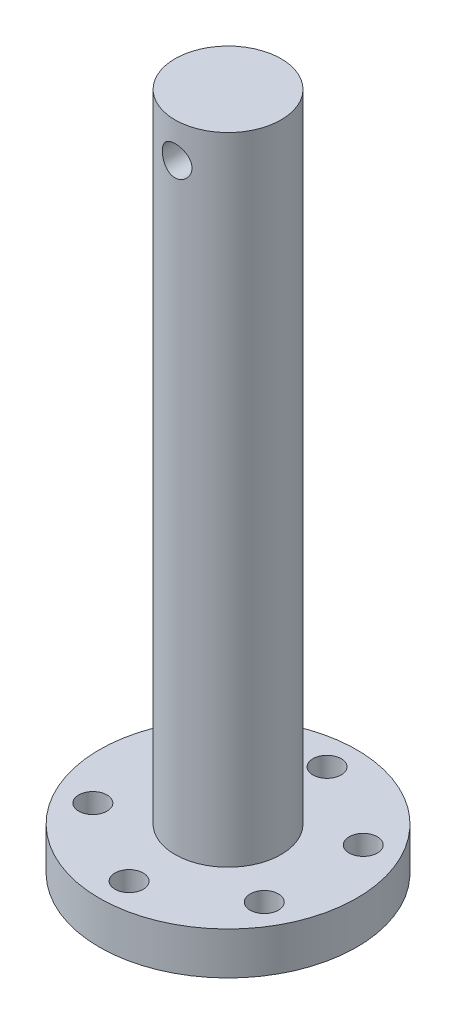
from build123d import *

# Parameters (mm, degrees)
SKETCH1_R           = 18.2
BOSS_EXTRUDE1_DEPTH = 6
SKETCH3_R           = 2
CUT_EXTRUDE1_DEPTH  = 10
CIRPATTERN1_COUNT   = 6
SKETCH4_R           = 7.5
BOSS_EXTRUDE2_DEPTH = 90
SKETCH9_R           = 2.1
CUT_EXTRUDE2_DEPTH  = 26.7


with BuildPart() as part:
    # Sketch1 → Boss-Extrude1 (new body)
    with BuildSketch(Plane(origin=(0, 0, 0), x_dir=(1, 0, 0), z_dir=(0, 1, 0))):
        Circle(SKETCH1_R)
    extrude(amount=BOSS_EXTRUDE1_DEPTH)

    # Sketch3 → Cut-Extrude1 (cut)
    with BuildSketch(Plane(origin=(0, 6, 0), x_dir=(1, 0, 0), z_dir=(0, 1, 0))):
        with Locations((0, 14)):
            Circle(SKETCH3_R)
    cut_extrude1 = extrude(amount=-CUT_EXTRUDE1_DEPTH, mode=Mode.SUBTRACT)

    # CirPattern1: Cut-Extrude1 ×6 about axis
    cirpattern1_axis = Axis((0, 0, 0), (0, 1, 0))
    for i in range(1, CIRPATTERN1_COUNT):
        add(cut_extrude1.rotate(cirpattern1_axis, i * 360 / CIRPATTERN1_COUNT), mode=Mode.SUBTRACT)

    # Sketch4 → Boss-Extrude2 (add)
    with BuildSketch(Plane(origin=(0, 6, 0), x_dir=(1, 0, 0), z_dir=(0, 1, 0))):
        Circle(SKETCH4_R)
    extrude(amount=BOSS_EXTRUDE2_DEPTH)

    # Sketch9 → Cut-Extrude2 (cut, through all)
    with BuildSketch(Plane(origin=(0, 0, -7.5), x_dir=(-1, 0, 0), z_dir=(0, 0, -1))):
        with Locations((0, 91)):
            Circle(SKETCH9_R)
    extrude(amount=-CUT_EXTRUDE2_DEPTH, mode=Mode.SUBTRACT)


solid = part.part
